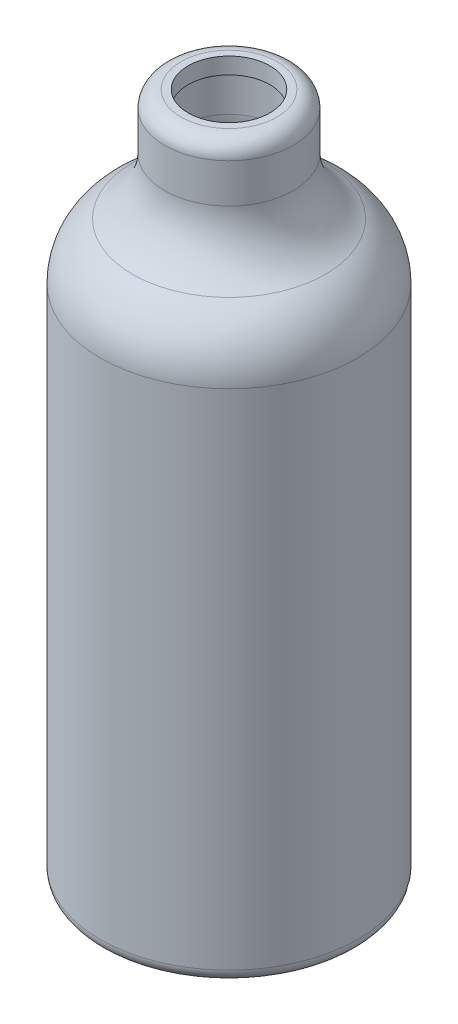
from build123d import *

# Parameters (mm, degrees)
SKETCH2_R          = 7.9375
CUT_EXTRUDE1_DEPTH = 12.7


with BuildPart() as part:
    # Sketch1 → Revolve-Thin2 (revolve)
    with BuildSketch(Plane.XY):
        with BuildLine():
            Line((0, 0), (22.46, 0))
            ThreePointArc((22.46, 0), (24.256051224, 0.743948776), (25, 2.54))
            Line((25, 2.54), (25, 100.324643513))
            ThreePointArc((25, 100.324643513), (23.327352357, 106.624445097), (18.75, 111.264821756))
            ThreePointArc((18.75, 111.264821756), (14.172647643, 115.905198416), (12.5, 122.205))
            Line((12.5, 122.205), (12.5, 129.825))
            ThreePointArc((12.5, 129.825), (11.57006403, 132.07006403), (9.325, 133))
            Line((9.325, 133), (0, 133))
            Line((0, 133), (0, 129.825))
            Line((0, 129.825), (9.325, 129.825))
            Line((9.325, 129.825), (9.325, 122.205))
            ThreePointArc((9.325, 122.205), (11.415809554, 114.33024802), (17.1375, 108.529777196))
            ThreePointArc((17.1375, 108.529777196), (20.570514268, 105.049494701), (21.825, 100.324643513))
            Line((21.825, 100.324643513), (21.825, 3.175))
            Line((21.825, 3.175), (0, 3.175))
            Line((0, 3.175), (0, 0))
        make_face()
    revolve(axis=Axis((0, 133, 0), (0, -1, 0)))

    # Sketch2 → Cut-Extrude1 (cut)
    with BuildSketch(Plane(origin=(0, 133, 0), x_dir=(1, 0, 0), z_dir=(0, 1, 0))):
        Circle(SKETCH2_R)
    extrude(amount=-CUT_EXTRUDE1_DEPTH, mode=Mode.SUBTRACT)


solid = part.part
